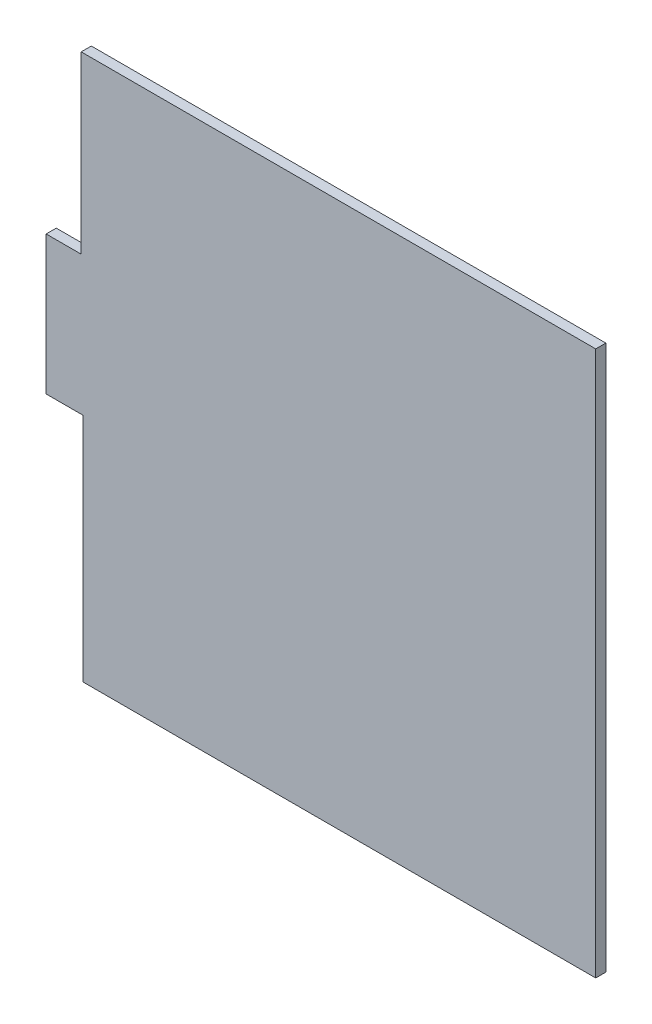
from build123d import *

# Parameters (mm, degrees)
BOSS_EXTRUDE1_DEPTH = 6.35


with BuildPart() as part:
    # Model → Boss-Extrude1 (new body)
    with BuildSketch(Plane.XY):
        Polygon((731.320358487, 258.065863271), (409.320358487, 258.065863271), (409.320358487, 403.065863271), (386.320358487, 403.065863271), (386.320358487, 490.065863271), (408.320358487, 490.065863271), (408.320358487, 600.065863271), (731.320358487, 600.065863271), align=None)
    extrude(amount=-BOSS_EXTRUDE1_DEPTH)


solid = part.part
